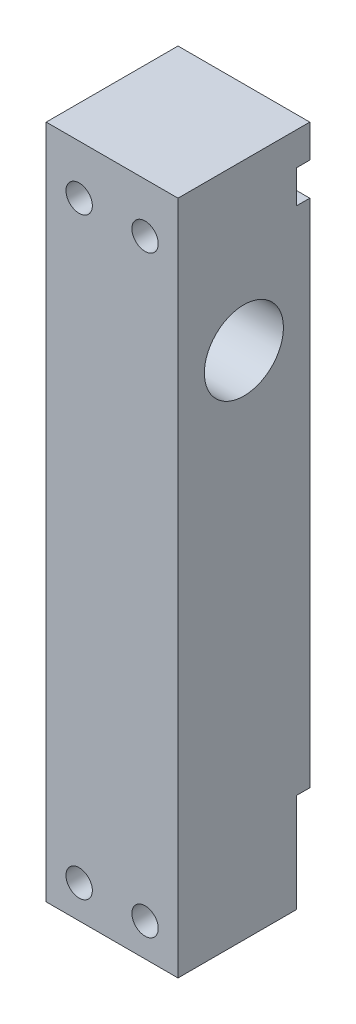
from build123d import *

# Parameters (mm, degrees)
SKETCH1_W           = 20
SKETCH1_H           = 120
SKETCH1_R           = 6
BOSS_EXTRUDE2_DEPTH = 20
SKETCH11_R          = 1
CUT_EXTRUDE2_DEPTH  = 124.288280059
SKETCH12_R          = 2
CUT_EXTRUDE3_DEPTH  = 5
SKETCH11_3_R        = 1
CUT_EXTRUDE4_DEPTH  = 124.288280059
SKETCH14_W          = 20
SKETCH14_H          = 5
SKETCH14_H_2        = 20
CUT_EXTRUDE6_DEPTH  = 2
SKETCH15_W          = 18
SKETCH15_H          = 5
CUT_EXTRUDE7_DEPTH  = 124.288280059
SKETCH16_W          = 20
SKETCH16_H          = 12.5
CUT_EXTRUDE8_DEPTH  = 124.288280059


with BuildPart() as part:
    # Sketch1 → Boss-Extrude2 (new body)
    with BuildSketch(Plane(origin=(0, 0, 0), x_dir=(0, 0, -1), z_dir=(1, 0, 0))):
        with Locations((10, 60)):
            Rectangle(SKETCH1_W, SKETCH1_H)
        with Locations((10, 82.5)):
            Circle(SKETCH1_R, mode=Mode.SUBTRACT)
    extrude(amount=-BOSS_EXTRUDE2_DEPTH)

    # Sketch11 → Cut-Extrude2 (cut, through all)
    with BuildSketch(Plane.XY):
        with Locations((-15, 10)):
            Circle(SKETCH11_R)
        with Locations((-5, 10)):
            Circle(SKETCH11_R)
    extrude(amount=-CUT_EXTRUDE2_DEPTH, mode=Mode.SUBTRACT)

    # Sketch12 → Cut-Extrude3 (cut)
    with BuildSketch(Plane.XY):
        with Locations((-15, 10)):
            Circle(SKETCH12_R)
        with Locations((-5, 10)):
            Circle(SKETCH12_R)
        with Locations((-15, 100)):
            Circle(SKETCH12_R)
        with Locations((-5, 100)):
            Circle(SKETCH12_R)
    extrude(amount=-CUT_EXTRUDE3_DEPTH, mode=Mode.SUBTRACT)

    # Sketch11_3 → Cut-Extrude4 (cut, through all)
    with BuildSketch(Plane.XY):
        with Locations((-15, 100)):
            Circle(SKETCH11_3_R)
        with Locations((-5, 100)):
            Circle(SKETCH11_3_R)
    extrude(amount=-CUT_EXTRUDE4_DEPTH, mode=Mode.SUBTRACT)

    # Sketch14 → Cut-Extrude6 (cut)
    with BuildSketch(Plane(origin=(0, 0, -20), x_dir=(-1, 0, 0), z_dir=(0, 0, -1))):
        with Locations((10, 100)):
            Rectangle(SKETCH14_W, SKETCH14_H)
        with Locations((10, 10)):
            Rectangle(SKETCH14_W, SKETCH14_H_2)
    extrude(amount=-CUT_EXTRUDE6_DEPTH, mode=Mode.SUBTRACT)

    # Sketch15 → Cut-Extrude7 (cut, through all)
    with BuildSketch(Plane(origin=(0, 0, 0), x_dir=(0, 0, -1), z_dir=(1, 0, 0))):
        with Locations((9, 2.5)):
            Rectangle(SKETCH15_W, SKETCH15_H)
    extrude(amount=-CUT_EXTRUDE7_DEPTH, mode=Mode.SUBTRACT)

    # Sketch16 → Cut-Extrude8 (cut, through all)
    with BuildSketch(Plane(origin=(0, 0, -20), x_dir=(-1, 0, 0), z_dir=(0, 0, -1))):
        with Locations((10, 113.75)):
            Rectangle(SKETCH16_W, SKETCH16_H)
    extrude(amount=-CUT_EXTRUDE8_DEPTH, mode=Mode.SUBTRACT)


solid = part.part
